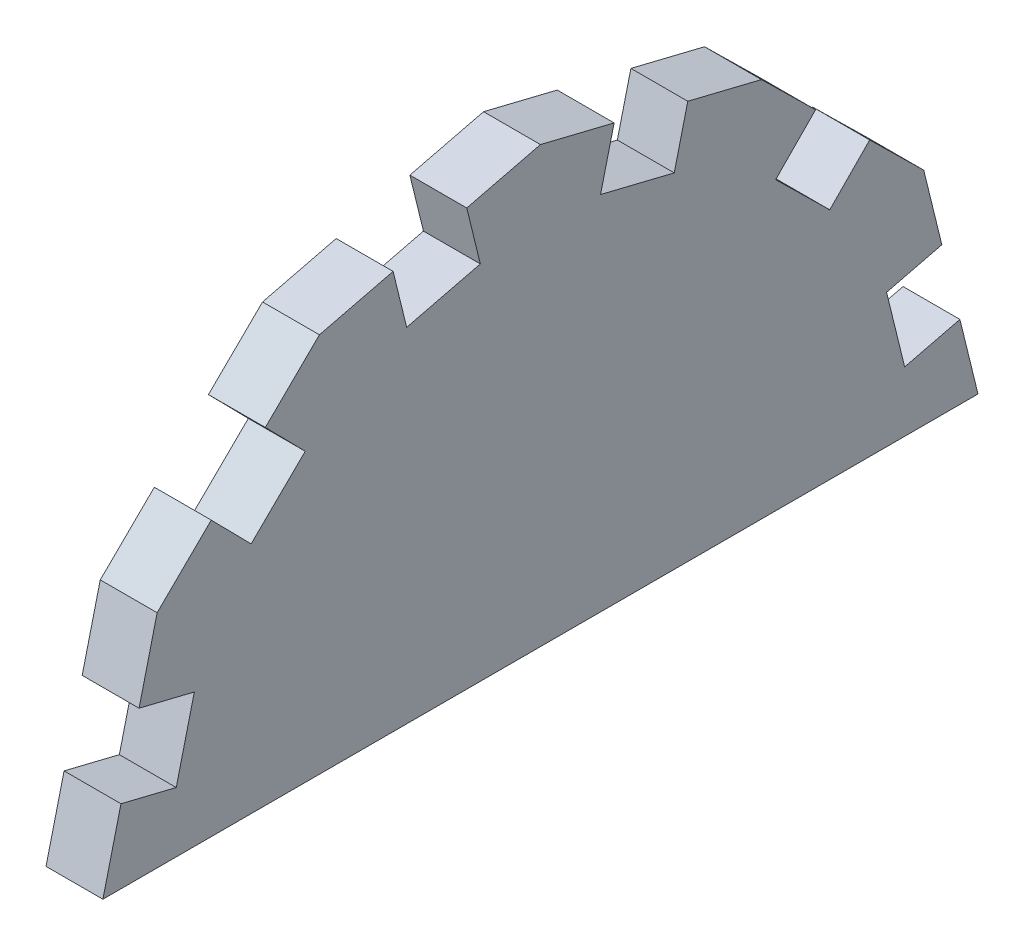
from build123d import *

# Parameters (mm, degrees)
BOSS_EXTRUDE1_DEPTH = 9.525
SKETCH3_W           = 9.525
SKETCH3_H           = 12.7
CUT_EXTRUDE1_DEPTH  = 9.525
SKETCH4_W           = 9.525
SKETCH4_H           = 12.7
CUT_EXTRUDE2_DEPTH  = 9.525
SKETCH5_W           = 9.525
SKETCH5_H           = 12.7
CUT_EXTRUDE3_DEPTH  = 9.525


with BuildPart() as part:
    # Sketch2 → Boss-Extrude1 (new body)
    with BuildSketch(Plane(origin=(0, 0, 0), x_dir=(0, 0, -1), z_dir=(1, 0, 0))):
        Polygon((-73.252839905, 0), (-64.170161704, 37.001553436), (-37.001553436, 63.712538532), (0, 72.795216732), (37.001553436, 63.712538532), (64.170161704, 37.001553436), (73.252839905, 0), align=None)
    extrude(amount=BOSS_EXTRUDE1_DEPTH)

    # Sketch3 → Cut-Extrude1 (cut)
    with BuildSketch(Plane(origin=(0, 16.959318632, 69.089878642), x_dir=(1, 0, 0), z_dir=(0, 0.238390504, 0.971169382))):
        with Locations((4.7625, 1.58721858)):
            Rectangle(SKETCH3_W, SKETCH3_H)
    cut_extrude1 = extrude(amount=-CUT_EXTRUDE1_DEPTH, mode=Mode.SUBTRACT)

    # Sketch4 → Cut-Extrude2 (cut)
    with BuildSketch(Plane(origin=(0, 50.895476621, 50.038202327), x_dir=(1, 0, 0), z_dir=(0, 0.713086831, 0.701075724))):
        with Locations((4.7625, -0.768006391)):
            Rectangle(SKETCH4_W, SKETCH4_H)
    cut_extrude2 = extrude(amount=-CUT_EXTRUDE2_DEPTH, mode=Mode.SUBTRACT)

    # Sketch5 → Cut-Extrude3 (cut)
    with BuildSketch(Plane(origin=(0, 68.658262209, 16.853370832), x_dir=(1, 0, 0), z_dir=(0, 0.971169382, 0.238390504))):
        with Locations((4.7625, -1.696311598)):
            Rectangle(SKETCH5_W, SKETCH5_H)
    cut_extrude3 = extrude(amount=-CUT_EXTRUDE3_DEPTH, mode=Mode.SUBTRACT)

    # Mirror1: Cut-Extrude1, Cut-Extrude2, Cut-Extrude3 across plane
    add(cut_extrude1.mirror(Plane.XY), mode=Mode.SUBTRACT)
    add(cut_extrude2.mirror(Plane.XY), mode=Mode.SUBTRACT)
    add(cut_extrude3.mirror(Plane.XY), mode=Mode.SUBTRACT)


solid = part.part
